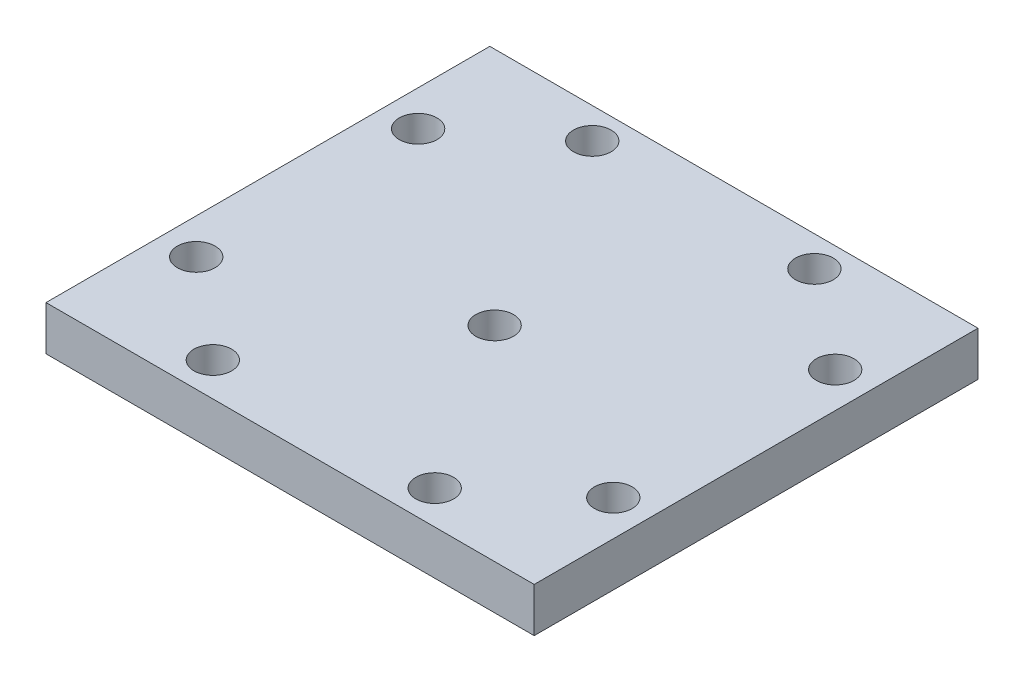
from build123d import *

# Parameters (mm, degrees)
CROQUIS1_R                              = 15.25
CROQUIS1_R_2                            = 2.125
SOPORTE_CAJA_REDUCTORA_DEPTH            = 20
CROQUIS3_R                              = 2.125
CORTAR_EXTRUIR1_DEPTH                   = 51.423828692
REDONDEO1_R                             = 5
BOSS_EXTRUDE1_DEPTH                     = 20
CUT_EXTRUDE1_REACH                      = 55.852
SKETCH2_R                               = 1.625
CUT_EXTRUDE2_DEPTH                      = 2
SKETCH4_R                               = 1.625
CUT_EXTRUDE3_DEPTH                      = 63.291652731
CUT_EXTRUDE4_START                      = -4.5
CUT_EXTRUDE4_DEPTH                      = 2
CROQUIS6_W                              = 4.75
CROQUIS6_H                              = 4.75
CORTAR_EXTRUIR17_DEPTH                  = 42.231056256
CROQUIS7_W                              = 60
CROQUIS7_H                              = 20
CORTAR_EXTRUIR18_DEPTH                  = 51.423828692
SALIENTE_EXTRUIR2_DEPTH                 = 49
SOPORTE_START                           = -15
SOPORTE_MOTOR_DEPTH                     = 15
CROQUIS12_R                             = 2.125
AGUJEROS_DE_SUJECION_A_BASE_DEPTH       = 84.087679592
TUERCA_START                            = -4
TUERCA_AGUJERO_DE_SUJECION_A_BASE_DEPTH = 10
SALIENTE_EXTRUIR4_DEPTH                 = 15
CORTAR_EXTRUIR19_DEPTH                  = 25
CROQUIS14_W                             = 50
CROQUIS14_H                             = 118
CORTAR_EXTRUIR22_DEPTH                  = 146.556045907
CROQUIS15_W                             = 10
CROQUIS15_H                             = 7
CORTAR_EXTRUIR23_DEPTH                  = 42.231056256
CORTAR_EXTRUIR24_DEPTH                  = 42.231056256
CROQUIS18_W                             = 40
CROQUIS18_H                             = 10
CORTAR_EXTRUIR25_DEPTH                  = 44.27311521
SALIENTE_EXTRUIR5_DEPTH                 = 10
CROQUIS20_R                             = 1
CORTAR_EXTRUIR26_DEPTH                  = 49.229270158
CORTAR_EXTRUIR27_REACH                  = 62.959
CORTAR_EXTRUIR27_END_RADIUS             = 15.25
CROQUIS21_R                             = 1.625
CROQUIS22_R                             = 2.125
CROQUIS22_R_2                           = 1
SALIENTE_EXTRUIR6_DEPTH                 = 10
CROQUIS23_R                             = 1.625
CORTAR_EXTRUIR28_DEPTH                  = 52.269508521
CORTAR_EXTRUIR29_START                  = -3
CORTAR_EXTRUIR29_DEPTH                  = 10
SALIENTE_EXTRUIR7_DEPTH                 = 10
CORTAR_EXTRUIR30_REACH                  = 72.235
CROQUIS27_R                             = 1.625
CORTAR_EXTRUIR31_REACH                  = 75.235
CORTAR_EXTRUIR31_START                  = -3
CORTAR_EXTRUIR32_REACH                  = 58.612
CROQUIS29_R                             = 1.625
CORTAR_EXTRUIR33_REACH                  = 61.112
CORTAR_EXTRUIR33_START                  = -2.5
CROQUIS35_W                             = 13.305418987
CROQUIS35_H                             = 6.826864192
CORTAR_EXTRUIR34_DEPTH                  = 63.931555098
CORTAR_EXTRUIR34_DEPTH_BACK             = 63.931555098
CORTAR_EXTRUIR35_START                  = -3
CORTAR_EXTRUIR35_DEPTH                  = 10
SALIENTE_EXTRUIR8_DEPTH                 = 10
SALIENTE_EXTRUIR9_DEPTH                 = 13
SALIENTE_EXTRUIR10_DEPTH                = 3
CROQUIS40_W                             = 106.583537839
CROQUIS40_H                             = 47.391515964
CORTAR_EXTRUIR36_DEPTH                  = 80.887064817
CORTAR_EXTRUIR36_DEPTH_BACK             = 80.887064817
CORTAR_EXTRUIR37_DEPTH                  = 67.2524009
CORTAR_EXTRUIR37_DEPTH_BACK             = 67.2524009
CORTAR_EXTRUIR38_DEPTH                  = 79.704784639
CORTAR_EXTRUIR38_DEPTH_BACK             = 79.704784639
SALIENTE_EXTRUIR11_DEPTH                = 10
CORTAR_EXTRUIR39_DEPTH                  = 63.9908649
CROQUIS45_W                             = 31.470301378
CROQUIS45_H                             = 10
CROQUIS45_R                             = 1.625
SALIENTE_EXTRUIR12_DEPTH                = 2.5
SALIENTE_EXTRUIR13_DEPTH                = 10
CORTAR_EXTRUIR40_START                  = -2
CROQUIS47_R                             = 1.625
CORTAR_EXTRUIR40_DEPTH                  = 10
CORTAR_EXTRUIR41_START                  = -12
CROQUIS48_R                             = 1.625
CORTAR_EXTRUIR41_DEPTH                  = 12
CROQUIS49_W                             = 34.796066513
CROQUIS49_H                             = 42.211026982
CORTAR_EXTRUIR42_DEPTH                  = 52.795622989
CORTAR_EXTRUIR42_DEPTH_BACK             = 52.795622989
CROQUIS51_R                             = 15.25
CROQUIS51_R_2                           = 14.25
SALIENTE_EXTRUIR14_DEPTH                = 10
CORTAR_EXTRUIR43_DEPTH                  = 10
CORTAR_EXTRUIR44_DEPTH                  = 10
CORTAR_EXTRUIR45_DEPTH                  = 10
SALIENTE_EXTRUIR15_DEPTH                = 10
CROQUIS56_W                             = 55
CROQUIS56_H                             = 50
CROQUIS56_R                             = 2.125
SALIENTE_EXTRUIR16_DEPTH                = 5
CROQUIS57_W                             = 42.651963039
CROQUIS57_H                             = 12.802181648
CORTAR_EXTRUIR46_DEPTH                  = 71.545387859
CORTAR_EXTRUIR46_DEPTH_BACK             = 71.545387859
CROQUIS58_R                             = 2.125
CORTAR_EXTRUIR47_DEPTH                  = 5


with BuildPart() as part:
    # Croquis1 → Soporte caja reductora (new body)
    with BuildSketch(Plane(origin=(0, 0, 0), x_dir=(1, 0, 0), z_dir=(0, 1, 0))):
        Polygon((-30, -15.25), (-20, -15.25), (-20, -20), (20, -20), (20, -15.25), (30, -15.25), (30, -7.25), (20, -4.25), (20, 20), (-20, 20), (-20, -4.25), (-30, -7.25), align=None)
        with Locations(Location((0, 0, 0), (0, 0, 270))):
            Circle(CROQUIS1_R, mode=Mode.SUBTRACT)
        with Locations(Location((-15, 15, 0), (0, 0, 270))):
            Circle(CROQUIS1_R_2, mode=Mode.SUBTRACT)
        with Locations(Location((15, 15, 0), (0, 0, 270))):
            Circle(CROQUIS1_R_2, mode=Mode.SUBTRACT)
    extrude(amount=-SOPORTE_CAJA_REDUCTORA_DEPTH)

    # Croquis3 → Cortar-Extruir1 (cut, through all)
    with BuildSketch(Plane.XY.offset(15.25)):
        with Locations((-23.5, -10)):
            Circle(CROQUIS3_R)
        with Locations((23.5, -10)):
            Circle(CROQUIS3_R)
    extrude(amount=-CORTAR_EXTRUIR1_DEPTH, mode=Mode.SUBTRACT)

    # Redondeo1
    redondeo1_edges = [part.edges().sort_by_distance(p)[0] for p in [
        (-20, -10, -20),
        (20, -10, -20),
    ]]
    fillet(redondeo1_edges, radius=REDONDEO1_R)

    # Sketch1 → Boss-Extrude1 (add)
    with BuildSketch(Plane(origin=(0, 0, 0), x_dir=(1, 0, 0), z_dir=(0, 1, 0))):
        with BuildLine():
            Line((25.5, 15), (20, 15))
            ThreePointArc((20, 15), (18.535533906, 18.535533906), (15, 20))
            Line((15, 20), (30, 20))
            Line((30, 20), (30, 8))
            Line((30, 8), (25.5, 8))
            Line((25.5, 8), (25.5, 15))
        make_face()
    extrude(amount=-BOSS_EXTRUDE1_DEPTH)

    # Sketch2 → Cut-Extrude1 (cut, up to next)
    with BuildSketch(Plane(origin=(0, 0, -20), x_dir=(-1, 0, 0), z_dir=(0, 0, -1)), mode=Mode.PRIVATE) as cut_extrude1_sk1:
        with Locations((-22.75, -10)):
            Circle(SKETCH2_R)
    cut_extrude1_tool1 = extrude(cut_extrude1_sk1.sketch, amount=-CUT_EXTRUDE1_REACH, mode=Mode.PRIVATE) & part.part
    add(cut_extrude1_tool1.solids().sort_by_distance((22.75, -10, -20))[0], mode=Mode.SUBTRACT)

    # Sketch3 → Cut-Extrude2 (cut)
    with BuildSketch(Plane.XY.offset(-15)):
        Polygon((20, -11.58771324), (22.75, -13.175426481), (25.5, -11.58771324), (25.5, -8.41228676), (22.75, -6.824573519), (20, -8.41228676), align=None)
    extrude(amount=-CUT_EXTRUDE2_DEPTH, mode=Mode.SUBTRACT)

    # Sketch4 → Cut-Extrude3 (cut, through all)
    with BuildSketch(Plane.ZY.offset(-25.5)):
        with Locations((-12.25, -10)):
            Circle(SKETCH4_R)
    extrude(amount=-CUT_EXTRUDE3_DEPTH, mode=Mode.SUBTRACT)

    # Sketch5 → Cut-Extrude4 (cut)
    with BuildSketch(Plane(origin=(30, 0, 0), x_dir=(0, 0, -1), z_dir=(1, 0, 0)).offset(CUT_EXTRUDE4_START)):
        Polygon((15, -11.58771324), (15, -8.41228676), (12.25, -6.824573519), (9.5, -8.41228676), (9.5, -11.58771324), (12.25, -13.175426481), align=None)
    extrude(amount=CUT_EXTRUDE4_DEPTH, mode=Mode.SUBTRACT)

    # Croquis6 → Cortar-Extruir17 (cut, through all)
    with BuildSketch(Plane(origin=(0, 0, 0), x_dir=(1, 0, 0), z_dir=(0, 1, 0))):
        Polygon((0, -15.25), (-15.25, -15.25), (-15.25, -20), (15.25, -20), (15.25, -15.25), align=None)
        with Locations((-17.625, -17.625)):
            Rectangle(CROQUIS6_W, CROQUIS6_H)
        with BuildLine():
            ThreePointArc((0, -15.25), (-10.783378413, -10.783378413), (-15.25, 0))
            Line((-15.25, 0), (-15.25, -15.25))
            Line((-15.25, -15.25), (0, -15.25))
        make_face()
        with BuildLine():
            Line((15.25, -15.25), (15.25, 0))
            ThreePointArc((15.25, 0), (10.783378413, -10.783378413), (0, -15.25))
            Line((0, -15.25), (15.25, -15.25))
        make_face()
        with Locations((17.625, -17.625)):
            Rectangle(CROQUIS6_W, CROQUIS6_H)
    extrude(amount=-CORTAR_EXTRUIR17_DEPTH, mode=Mode.SUBTRACT)


with BuildPart() as body_2:
    # Simetría1: mirrored copy
    add(part.part.mirror(Plane.ZX))

    # Croquis8 → Saliente-Extruir2 (add)
    with BuildSketch(Plane(origin=(0, 20, 0), x_dir=(1, 0, 0), z_dir=(0, 1, 0))):
        with BuildLine():
            Line((-12.664515522, 20), (-11.040489496, 13.939052358))
            Line((-11.040489496, 13.939052358), (-10.315162126, 11.232093763))
            ThreePointArc((-10.315162126, 11.232093763), (0, 15.25), (10.315162126, 11.232093763))
            Line((10.315162126, 11.232093763), (10.817418481, 13.87928066))
            Line((10.817418481, 13.87928066), (11.978715476, 20))
            Line((11.978715476, 20), (-12.664515522, 20))
        make_face()
    extrude(amount=SALIENTE_EXTRUIR2_DEPTH)

    # Croquis9 → Soporte motor (add)
    with BuildSketch(Plane(origin=(0, 69, 0), x_dir=(1, 0, 0), z_dir=(0, 1, 0)).offset(SOPORTE_START)):
        with BuildLine():
            Line((-20, 15), (-20, -4.25))
            Line((-20, -4.25), (-30, -7.25))
            Line((-30, -7.25), (-30, -15.25))
            Line((-30, -15.25), (0, -15.25))
            Line((0, -15.25), (0, -14.75))
            ThreePointArc((0, -14.75), (-10.429825023, 10.429825023), (14.75, 0))
            Line((14.75, 0), (20, 0))
            Line((20, 0), (20, 13.936837101))
            Line((20, 13.936837101), (12.664515522, 20))
            Line((12.664515522, 20), (-15, 20))
            ThreePointArc((-15, 20), (-18.535533906, 18.535533906), (-20, 15))
        make_face()
    extrude(amount=-SOPORTE_MOTOR_DEPTH)

    # Croquis12 → Agujeros de sujecion a base (cut, through all)
    with BuildSketch(Plane.XY.offset(15.25)):
        with Locations((-23.5, 46.5)):
            Circle(CROQUIS12_R)
    extrude(amount=-AGUJEROS_DE_SUJECION_A_BASE_DEPTH, mode=Mode.SUBTRACT)

    # Croquis13 → Tuerca Agujero de sujecion a base (cut)
    with BuildSketch(Plane.XY.offset(15.25).offset(TUERCA_START)):
        Polygon((-20, 44.479274058), (-20, 48.520725942), (-23.5, 50.541451884), (-27, 48.520725942), (-27, 44.479274058), (-23.5, 42.458548116), align=None)
    extrude(amount=-TUERCA_AGUJERO_DE_SUJECION_A_BASE_DEPTH, mode=Mode.SUBTRACT)

    # Croquis10 → Saliente-Extruir4 (add)
    with BuildSketch(Plane(origin=(0, 69, 0), x_dir=(1, 0, 0), z_dir=(0, 1, 0))):
        with BuildLine():
            ThreePointArc((10.315162126, 11.232093763), (0, 15.25), (-10.315162126, 11.232093763))
            Line((-10.315162126, 11.232093763), (-10.16850369, 10.684757026))
            ThreePointArc((-10.16850369, 10.684757026), (0, 14.75), (10.16850369, 10.684757026))
            Line((10.16850369, 10.684757026), (10.315162126, 11.232093763))
        make_face()
    extrude(amount=-SALIENTE_EXTRUIR4_DEPTH)

    # Croquis11 → Cortar-Extruir19 (cut)
    with BuildSketch(Plane.XZ):
        with BuildLine():
            Line((15.25, 4.25), (20, 4.25))
            Line((20, 4.25), (21.972856468, 4.84185694))
            ThreePointArc((21.972856468, 4.84185694), (19.948931102, 10.40625523), (16.543503257, 15.25))
            Line((16.543503257, 15.25), (15.25, 15.25))
            Line((15.25, 15.25), (15.25, 4.25))
        make_face()
        with BuildLine():
            Line((21.972856468, 4.84185694), (30, 7.25))
            Line((30, 7.25), (30, 15.25))
            Line((30, 15.25), (16.543503257, 15.25))
            ThreePointArc((16.543503257, 15.25), (19.948931102, 10.40625523), (21.972856468, 4.84185694))
        make_face()
        with BuildLine():
            ThreePointArc((20, -15), (18.535533906, -18.535533906), (15, -20))
            Line((15, -20), (30, -20))
            Line((30, -20), (30, -8))
            Line((30, -8), (25.5, -8))
            Line((25.5, -8), (25.5, -15))
            Line((25.5, -15), (20, -15))
        make_face()
    extrude(amount=-CORTAR_EXTRUIR19_DEPTH, mode=Mode.SUBTRACT)

    # Simetría2: body 2 across face


with BuildPart() as part_1:
    add(part.part)

    # Croquis7 → Cortar-Extruir18 (cut, through all)
    with BuildSketch(Plane(origin=(0, 0, -20), x_dir=(-1, 0, 0), z_dir=(0, 0, -1))):
        with Locations((0, -10)):
            Rectangle(CROQUIS7_W, CROQUIS7_H)
    extrude(amount=-CORTAR_EXTRUIR18_DEPTH, mode=Mode.SUBTRACT)


with BuildPart() as body_2_1:
    add(body_2.part)
    add(body_2.part.mirror(Plane(origin=(-0.229209569, 69, -16.663998028), x_dir=(0, 0, 1), z_dir=(0, 1, 0))))

    # Croquis14 → Cortar-Extruir22 (cut, through all)
    with BuildSketch(Plane.XY.offset(15.25)):
        with Locations((-5, 79)):
            Rectangle(CROQUIS14_W, CROQUIS14_H)
    extrude(amount=-CORTAR_EXTRUIR22_DEPTH, mode=Mode.SUBTRACT)

    # Croquis15 → Cortar-Extruir23 (cut, through all)
    with BuildSketch(Plane.XZ):
        with Locations((-25, 7.75)):
            Rectangle(CROQUIS15_W, CROQUIS15_H)
    extrude(amount=-CORTAR_EXTRUIR23_DEPTH, mode=Mode.SUBTRACT)

    # Croquis16 → Cortar-Extruir24 (cut, through all)
    with BuildSketch(Plane.XZ):
        Polygon((-30, 15.25), (-15.25, 15.25), (-15.25, 12.75), (-20, 12.75), (-20, 11.25), (-30, 11.25), (-30, 12.75), align=None)
    extrude(amount=-CORTAR_EXTRUIR24_DEPTH, mode=Mode.SUBTRACT)

    # Croquis18 → Cortar-Extruir25 (cut, through all)
    with BuildSketch(Plane(origin=(0, 0, -20), x_dir=(-1, 0, 0), z_dir=(0, 0, -1))):
        with Locations((0, 5)):
            Rectangle(CROQUIS18_W, CROQUIS18_H)
    extrude(amount=-CORTAR_EXTRUIR25_DEPTH, mode=Mode.SUBTRACT)

    # Croquis19 → Saliente-Extruir5 (add)
    with BuildSketch(Plane(origin=(0, 20, 0), x_dir=(1, 0, 0), z_dir=(0, 1, 0))):
        Polygon((-20, -12.75), (-34, -12.75), (-34, -7.75), (-24, -7.75), (-20, -3.75), align=None)
    extrude(amount=-SALIENTE_EXTRUIR5_DEPTH)

    # Croquis20 → Cortar-Extruir26 (cut, through all)
    with BuildSketch(Plane(origin=(0, 0, 7.75), x_dir=(-1, 0, 0), z_dir=(0, 0, -1))):
        with Locations((29, 15)):
            Circle(CROQUIS20_R)
    extrude(amount=-CORTAR_EXTRUIR26_DEPTH, mode=Mode.SUBTRACT)

    # Cortar-Extruir27: up to this cylinder (the profile starts outside it)
    cortar_extruir27_end = Plane(origin=(0, 15, 0), z_dir=(0, -1, 0)) * Cylinder(CORTAR_EXTRUIR27_END_RADIUS, 157.418, mode=Mode.PRIVATE)
    # Croquis21 → Cortar-Extruir27 (cut, up to the surface)
    with BuildSketch(Plane(origin=(20, 0, 0), x_dir=(0, 0, -1), z_dir=(1, 0, 0)), mode=Mode.PRIVATE) as cortar_extruir27_sk1:
        with Locations((4.75, 15)):
            Circle(CROQUIS21_R)
    cortar_extruir27_tool1 = extrude(cortar_extruir27_sk1.sketch, amount=-CORTAR_EXTRUIR27_REACH, mode=Mode.PRIVATE) - cortar_extruir27_end
    add(cortar_extruir27_tool1.solids().sort_by_distance((20, 15, -4.75))[0], mode=Mode.SUBTRACT)

    # Croquis22 → Saliente-Extruir6 (add)
    with BuildSketch(Plane.XZ.offset(-10)):
        with Locations((-15, -15)):
            Circle(CROQUIS22_R)
        with Locations(Location((-15, -15, 0), (0, 0, 270))):
            Circle(CROQUIS22_R_2, mode=Mode.SUBTRACT)
        with Locations((15, -15)):
            Circle(CROQUIS22_R)
        with Locations(Location((15, -15, 0), (0, 0, 270))):
            Circle(CROQUIS22_R_2, mode=Mode.SUBTRACT)
    extrude(amount=-SALIENTE_EXTRUIR6_DEPTH)

    # Croquis23 → Cortar-Extruir28 (cut, through all)
    with BuildSketch(Plane(origin=(0, 0, -20), x_dir=(-1, 0, 0), z_dir=(0, 0, -1))):
        with Locations((0, 15)):
            Circle(CROQUIS23_R)
    extrude(amount=-CORTAR_EXTRUIR28_DEPTH, mode=Mode.SUBTRACT)

    # Croquis24 → Cortar-Extruir29 (cut)
    with BuildSketch(Plane(origin=(0, 0, -20), x_dir=(-1, 0, 0), z_dir=(0, 0, -1)).offset(CORTAR_EXTRUIR29_START)):
        Polygon((1.58771324, 12.25), (3.175426481, 15), (1.58771324, 17.75), (-1.58771324, 17.75), (-3.175426481, 15), (-1.58771324, 12.25), align=None)
    extrude(amount=-CORTAR_EXTRUIR29_DEPTH, mode=Mode.SUBTRACT)

    # Croquis26 → Saliente-Extruir7 (add)
    with BuildSketch(Plane.XZ.offset(-10)):
        Polygon((-34, 7.75), (-34, 12.75), (-58.825, 12.75), (-39.160527763, -4.104491148), (-20, -4.104491148), (-20, -0.104491148), (-35.732113118, -0.104491148), (-29, 7.75), align=None)
        Polygon((-34.268209086, 7.75), (-39.594516123, 1.535690951), (-46.844874897, 7.75), align=None, mode=Mode.SUBTRACT)
    extrude(amount=-SALIENTE_EXTRUIR7_DEPTH)

    # Croquis27 → Cortar-Extruir30 (cut, up to next)
    with BuildSketch(Plane.XY.offset(12.75), mode=Mode.PRIVATE) as cortar_extruir30_sk1:
        with Locations((-40.544874897, 15)):
            Circle(CROQUIS27_R)
    cortar_extruir30_tool1 = extrude(cortar_extruir30_sk1.sketch, amount=-CORTAR_EXTRUIR30_REACH, mode=Mode.PRIVATE) & body_2_1.part
    # Croquis27 → Cortar-Extruir30 (cut, up to next)
    with BuildSketch(Plane.XY.offset(12.75), mode=Mode.PRIVATE) as cortar_extruir30_sk2:
        with Locations((-29, 15)):
            Circle(CROQUIS27_R)
    cortar_extruir30_tool2 = extrude(cortar_extruir30_sk2.sketch, amount=-CORTAR_EXTRUIR30_REACH, mode=Mode.PRIVATE) & body_2_1.part
    add(cortar_extruir30_tool1.solids().sort_by_distance((-40.544875, 15, 12.75))[0], mode=Mode.SUBTRACT)
    add(cortar_extruir30_tool2.solids().sort_by_distance((-29, 15, 12.75))[0], mode=Mode.SUBTRACT)

    # Croquis28 → Cortar-Extruir31 (cut, up to next)
    with BuildSketch(Plane.XY.offset(12.75).offset(CORTAR_EXTRUIR31_START), mode=Mode.PRIVATE) as cortar_extruir31_sk1:
        Polygon((-38.957161657, 12.25), (-37.369448416, 15), (-38.957161657, 17.75), (-42.132588137, 17.75), (-43.720301378, 15), (-42.132588137, 12.25), align=None)
    cortar_extruir31_tool1 = extrude(cortar_extruir31_sk1.sketch, amount=-CORTAR_EXTRUIR31_REACH, mode=Mode.PRIVATE) & body_2_1.part
    # Croquis28 → Cortar-Extruir31 (cut, up to next)
    with BuildSketch(Plane.XY.offset(12.75).offset(CORTAR_EXTRUIR31_START), mode=Mode.PRIVATE) as cortar_extruir31_sk2:
        Polygon((-27.41228676, 12.25), (-25.824573519, 15), (-27.41228676, 17.75), (-30.58771324, 17.75), (-32.175426481, 15), (-30.58771324, 12.25), align=None)
    cortar_extruir31_tool2 = extrude(cortar_extruir31_sk2.sketch, amount=-CORTAR_EXTRUIR31_REACH, mode=Mode.PRIVATE) & body_2_1.part
    add(cortar_extruir31_tool1.solids().sort_by_distance((-40.544875, 15, 9.75))[0], mode=Mode.SUBTRACT)
    add(cortar_extruir31_tool2.solids().sort_by_distance((-29, 15, 9.75))[0], mode=Mode.SUBTRACT)

    # Croquis29 → Cortar-Extruir32 (cut, up to next)
    with BuildSketch(Plane(origin=(-18.612848159, 0, -21.715982563), x_dir=(-0.7592713073348843, 0, 0.6507742172658468), z_dir=(-0.6507742172658468, 0, -0.7592713073348843)), mode=Mode.PRIVATE) as cortar_extruir32_sk1:
        with Locations((33.812368097, 15)):
            Circle(CROQUIS29_R)
    cortar_extruir32_tool1 = extrude(cortar_extruir32_sk1.sketch, amount=-CORTAR_EXTRUIR32_REACH, mode=Mode.PRIVATE) & body_2_1.part
    add(cortar_extruir32_tool1.solids().sort_by_distance((-44.285609, 15, 0.288235))[0], mode=Mode.SUBTRACT)

    # Croquis31 → Cortar-Extruir33 (cut, up to next)
    with BuildSketch(Plane(origin=(-18.612848159, 0, -21.715982563), x_dir=(-0.7592713073348843, 0, 0.6507742172658468), z_dir=(-0.6507742172658468, 0, -0.7592713073348843)).offset(CORTAR_EXTRUIR33_START), mode=Mode.PRIVATE) as cortar_extruir33_sk1:
        Polygon((36.562368097, 16.58771324), (33.812368097, 18.175426481), (31.062368097, 16.58771324), (31.062368097, 13.41228676), (33.812368097, 11.824573519), (36.562368097, 13.41228676), align=None)
    cortar_extruir33_tool1 = extrude(cortar_extruir33_sk1.sketch, amount=-CORTAR_EXTRUIR33_REACH, mode=Mode.PRIVATE) & body_2_1.part
    add(cortar_extruir33_tool1.solids().sort_by_distance((-42.658674, 15, 2.186413))[0], mode=Mode.SUBTRACT)

    # Croquis35 → Cortar-Extruir34 (cut, two sides)
    with BuildSketch(Plane(origin=(0, 20, 0), x_dir=(1, 0, 0), z_dir=(0, 1, 0))) as cortar_extruir34_sk:
        with Locations((17.04227466, -3.413432096)):
            Rectangle(CROQUIS35_W, CROQUIS35_H)
    extrude(amount=CORTAR_EXTRUIR34_DEPTH, mode=Mode.SUBTRACT)
    extrude(cortar_extruir34_sk.sketch, amount=-CORTAR_EXTRUIR34_DEPTH_BACK, mode=Mode.SUBTRACT)

    # Croquis36 → Cortar-Extruir35 (cut)
    with BuildSketch(Plane(origin=(20, 0, 0), x_dir=(0, 0, -1), z_dir=(1, 0, 0)).offset(CORTAR_EXTRUIR35_START)):
        Polygon((7.5, 16.58771324), (4.75, 18.175426481), (2, 16.58771324), (2, 13.41228676), (4.75, 11.824573519), (7.5, 13.41228676), align=None)
    extrude(amount=-CORTAR_EXTRUIR35_DEPTH, mode=Mode.SUBTRACT)

    # Croquis37 → Saliente-Extruir8 (add)
    with BuildSketch(Plane.XZ.offset(-10)):
        Polygon((-39.160527763, -4.104491148), (-20.614919368, -20), (-15, -20), (-19.558128305, -15.637570403), (-33.014002756, -4.104491148), align=None)
    extrude(amount=-SALIENTE_EXTRUIR8_DEPTH)

    # Croquis38 → Saliente-Extruir9 (add)
    with BuildSketch(Plane.XZ.offset(-10)):
        Polygon((-58.825, 12.75), (-38.825, 12.75), (-38.825, 9.75), (-55.324839942, 9.75), align=None)
    extrude(amount=SALIENTE_EXTRUIR9_DEPTH)

    # Croquis39 → Saliente-Extruir10 (add)
    with BuildSketch(Plane.XZ.offset(-10)):
        Polygon((-38.825, 9.75), (-38.825, 7.75), (-38.825, 5.75), (-50.657959865, 5.75), (-52.991399903, 7.75), (-55.324839942, 9.75), align=None)
    extrude(amount=SALIENTE_EXTRUIR10_DEPTH)

    # Simetría3: body 2 across face


with BuildPart() as body_2_2:
    add(body_2_1.part)
    add(body_2_1.part.mirror(Plane(origin=(-18.003999227, 20, -4.220503046), x_dir=(0, 0, 1), z_dir=(0, 1, 0))))

    # Croquis40 → Cortar-Extruir36 (cut, two sides)
    with BuildSketch(Plane(origin=(0, 0, -20), x_dir=(-1, 0, 0), z_dir=(0, 0, -1))) as cortar_extruir36_sk:
        with Locations((22.395502026, -3.695757982)):
            Rectangle(CROQUIS40_W, CROQUIS40_H)
    extrude(amount=CORTAR_EXTRUIR36_DEPTH, mode=Mode.SUBTRACT)
    extrude(cortar_extruir36_sk.sketch, amount=-CORTAR_EXTRUIR36_DEPTH_BACK, mode=Mode.SUBTRACT)

    # Croquis41 → Cortar-Extruir37 (cut, two sides)
    with BuildSketch(Plane.XZ.offset(-20)) as cortar_extruir37_sk:
        Polygon((-19.992980133, -22.302484261), (-20, 3.75), (-24, 7.75), (-56.035110209, 7.75), align=None)
    extrude(amount=CORTAR_EXTRUIR37_DEPTH, mode=Mode.SUBTRACT)
    extrude(cortar_extruir37_sk.sketch, amount=-CORTAR_EXTRUIR37_DEPTH_BACK, mode=Mode.SUBTRACT)

    # Croquis42 → Cortar-Extruir38 (cut, two sides)
    with BuildSketch(Plane(origin=(0, 0, 9.75), x_dir=(-1, 0, 0), z_dir=(0, 0, -1))) as cortar_extruir38_sk:
        Polygon((46.720301378, 20), (46.720301378, 30), (38.825, 30), (33.492952769, 43.760628779), (49.525340398, 48.951442806), (67.200390695, 42.512205152), (65.906601328, 20), (51.713995885, 13.864168239), align=None)
    extrude(amount=CORTAR_EXTRUIR38_DEPTH, mode=Mode.SUBTRACT)
    extrude(cortar_extruir38_sk.sketch, amount=-CORTAR_EXTRUIR38_DEPTH_BACK, mode=Mode.SUBTRACT)

    # Croquis43 → Saliente-Extruir11 (add)
    with BuildSketch(Plane.XZ.offset(-20)):
        Polygon((-19.993600539, -20), (-46.720301378, 7.75), (-43.839252857, 10.524807997), (-17.112552018, -17.225192003), align=None)
    extrude(amount=-SALIENTE_EXTRUIR11_DEPTH)

    # Croquis44 → Cortar-Extruir39 (cut, through all)
    with BuildSketch(Plane(origin=(0, 0, 9.75), x_dir=(-1, 0, 0), z_dir=(0, 0, -1))):
        Polygon((38.957161657, 27.75), (37.369448416, 25), (38.957161657, 22.25), (42.132588137, 22.25), (43.720301378, 25), (42.132588137, 27.75), align=None)
    extrude(amount=CORTAR_EXTRUIR39_DEPTH, mode=Mode.SUBTRACT)

    # Croquis45 → Saliente-Extruir12 (add)
    with BuildSketch(Plane.XY.offset(12.75)):
        with Locations((-30.985150689, 25)):
            Rectangle(CROQUIS45_W, CROQUIS45_H)
        with Locations((-40.544874897, 25)):
            Circle(CROQUIS45_R, mode=Mode.SUBTRACT)
        with Locations((-29, 25)):
            Circle(CROQUIS45_R, mode=Mode.SUBTRACT)
    extrude(amount=SALIENTE_EXTRUIR12_DEPTH)

    # Croquis46 → Saliente-Extruir13 (add)
    with BuildSketch(Plane.XZ.offset(-20)):
        with BuildLine():
            Line((15.25, 0), (20, 0))
            Line((20, 0), (20, 15.25))
            Line((20, 15.25), (7.549834435, 15.25))
            Line((7.549834435, 15.25), (7.549834435, 13.25))
            ThreePointArc((7.549834435, 13.25), (13.185171124, 7.662490615), (15.25, 0))
        make_face()
        with BuildLine():
            Line((-15.25, 0), (-15.25, 15.25))
            Line((-15.25, 15.25), (-7.549834435, 15.25))
            Line((-7.549834435, 15.25), (-7.549834435, 13.25))
            ThreePointArc((-7.549834435, 13.25), (-13.185171124, 7.662490615), (-15.25, 0))
        make_face()
    extrude(amount=-SALIENTE_EXTRUIR13_DEPTH)

    # Croquis47 → Cortar-Extruir40 (cut)
    with BuildSketch(Plane.XY.offset(15.25).offset(CORTAR_EXTRUIR40_START)):
        Polygon((15.41228676, 22.352505966), (17, 25.102505966), (15.41228676, 27.852505966), (12.236860279, 27.852505966), (10.649147039, 25.102505966), (12.236860279, 22.352505966), align=None)
        with Locations((13.824573519, 25.102505966)):
            Circle(CROQUIS47_R, mode=Mode.SUBTRACT)
        Polygon((-12.236860279, 22.352505966), (-15.41228676, 22.352505966), (-17, 25.102505966), (-15.41228676, 27.852505966), (-12.236860279, 27.852505966), (-10.649147039, 25.102505966), align=None)
        with Locations(Location((-13.824573519, 25.102505966, 0), (0, 0, 131.421584744))):
            Circle(CROQUIS47_R, mode=Mode.SUBTRACT)
    extrude(amount=-CORTAR_EXTRUIR40_DEPTH, mode=Mode.SUBTRACT)

    # Croquis48 → Cortar-Extruir41 (cut)
    with BuildSketch(Plane.XY.offset(15.25).offset(CORTAR_EXTRUIR41_START)):
        with Locations((13.824573519, 25.102505966)):
            Circle(CROQUIS48_R)
        with Locations((-13.824573519, 25.102505966)):
            Circle(CROQUIS48_R)
    extrude(amount=CORTAR_EXTRUIR41_DEPTH, mode=Mode.SUBTRACT)

    # Croquis49 → Cortar-Extruir42 (cut, two sides)
    with BuildSketch(Plane.XZ.offset(-20)) as cortar_extruir42_sk:
        with Locations((-37.391633796, 1.105513491)):
            Rectangle(CROQUIS49_W, CROQUIS49_H)
    extrude(amount=CORTAR_EXTRUIR42_DEPTH, mode=Mode.SUBTRACT)
    extrude(cortar_extruir42_sk.sketch, amount=-CORTAR_EXTRUIR42_DEPTH_BACK, mode=Mode.SUBTRACT)

    # Croquis51 → Saliente-Extruir14 (add)
    with BuildSketch(Plane(origin=(0, 30, 0), x_dir=(1, 0, 0), z_dir=(0, 1, 0))):
        Circle(CROQUIS51_R)
        with Locations(Location((0, 0, 0), (0, 0, 270))):
            Circle(CROQUIS51_R_2, mode=Mode.SUBTRACT)
    extrude(amount=-SALIENTE_EXTRUIR14_DEPTH)

    # Croquis52 → Cortar-Extruir43 (cut)
    with BuildSketch(Plane(origin=(0, 0, 13.25), x_dir=(-1, 0, 0), z_dir=(0, 0, -1))):
        Polygon((-10.649147039, 25.102505966), (-12.236860279, 27.852505966), (-15.41228676, 27.852505966), (-17, 25.102505966), (-15.41228676, 22.352505966), (-12.236860279, 22.352505966), align=None)
        Polygon((17, 25.102505966), (15.41228676, 27.852505966), (12.236860279, 27.852505966), (10.649147039, 25.102505966), (12.236860279, 22.352505966), (15.41228676, 22.352505966), align=None)
    extrude(amount=CORTAR_EXTRUIR43_DEPTH, mode=Mode.SUBTRACT)

    # Croquis53 → Cortar-Extruir44 (cut)
    with BuildSketch(Plane.XY.offset(-17)):
        Polygon((3.175426481, 25), (1.58771324, 27.75), (-1.58771324, 27.75), (-3.175426481, 25), (-1.58771324, 22.25), (1.58771324, 22.25), align=None)
    extrude(amount=CORTAR_EXTRUIR44_DEPTH, mode=Mode.SUBTRACT)

    # Croquis54 → Cortar-Extruir45 (cut)
    with BuildSketch(Plane.ZY.offset(-17)):
        Polygon((-4.75, 28.175426481), (-7.5, 26.58771324), (-7.5, 23.41228676), (-4.75, 21.824573519), (-2, 23.41228676), (-2, 26.58771324), align=None)
    extrude(amount=CORTAR_EXTRUIR45_DEPTH, mode=Mode.SUBTRACT)

    # Croquis55 → Saliente-Extruir15 (add)
    with BuildSketch(Plane(origin=(0, 30, 0), x_dir=(1, 0, 0), z_dir=(0, 1, 0))):
        with BuildLine():
            Line((-7.549834435, -13.25), (-7.549834435, -15.25))
            Line((-7.549834435, -15.25), (0, -15.25))
            ThreePointArc((0, -15.25), (-3.905124838, -14.741522988), (-7.549834435, -13.25))
        make_face()
        with BuildLine():
            ThreePointArc((7.549834435, -13.25), (3.905124838, -14.741522988), (0, -15.25))
            Line((0, -15.25), (7.549834435, -15.25))
            Line((7.549834435, -15.25), (7.549834435, -13.25))
        make_face()
    extrude(amount=-SALIENTE_EXTRUIR15_DEPTH)

    # Croquis57 → Cortar-Extruir46 (cut, two sides)
    with BuildSketch(Plane.ZY.offset(27.5)) as cortar_extruir46_sk:
        with Locations((1.32598152, 23.598909176)):
            Rectangle(CROQUIS57_W, CROQUIS57_H)
    extrude(amount=CORTAR_EXTRUIR46_DEPTH, mode=Mode.SUBTRACT)
    extrude(cortar_extruir46_sk.sketch, amount=-CORTAR_EXTRUIR46_DEPTH_BACK, mode=Mode.SUBTRACT)


with BuildPart() as body_2_2_1:
    # Croquis56 → Saliente-Extruir16 (new body)
    with BuildSketch(Plane(origin=(0, 30, 0), x_dir=(1, 0, 0), z_dir=(0, 1, 0))):
        with Locations((0, 1.956478778)):
            Rectangle(CROQUIS56_W, CROQUIS56_H)
        with Locations(Location((0, 0, 0), (0, 0, 270))):
            Circle(CROQUIS56_R, mode=Mode.SUBTRACT)
    extrude(amount=SALIENTE_EXTRUIR16_DEPTH)

    # Croquis58 → Cortar-Extruir47 (cut)
    with BuildSketch(Plane.XZ.offset(-30)):
        with Locations(Location((-12.5, 19.25, 0), (0, 0, 270))):
            Circle(CROQUIS58_R)
        with Locations(Location((12.5, 19.25, 0), (0, 0, 270))):
            Circle(CROQUIS58_R)
        with Locations(Location((-12.5, -23.5, 0), (0, 0, 270))):
            Circle(CROQUIS58_R)
        with Locations(Location((12.5, -23.526519471, 0), (0, 0, 270))):
            Circle(CROQUIS58_R)
        with Locations(Location((-23.493600539, 10.125, 0), (0, 0, 270))):
            Circle(CROQUIS58_R)
        with Locations(Location((-23.493600539, -14.875, 0), (0, 0, 270))):
            Circle(CROQUIS58_R)
        with Locations(Location((23.493600539, -14.875, 0), (0, 0, 90))):
            Circle(CROQUIS58_R)
        with Locations(Location((23.493600539, 10.125, 0), (0, 0, 90))):
            Circle(CROQUIS58_R)
    extrude(amount=-CORTAR_EXTRUIR47_DEPTH, mode=Mode.SUBTRACT)


solid = body_2_2_1.part
